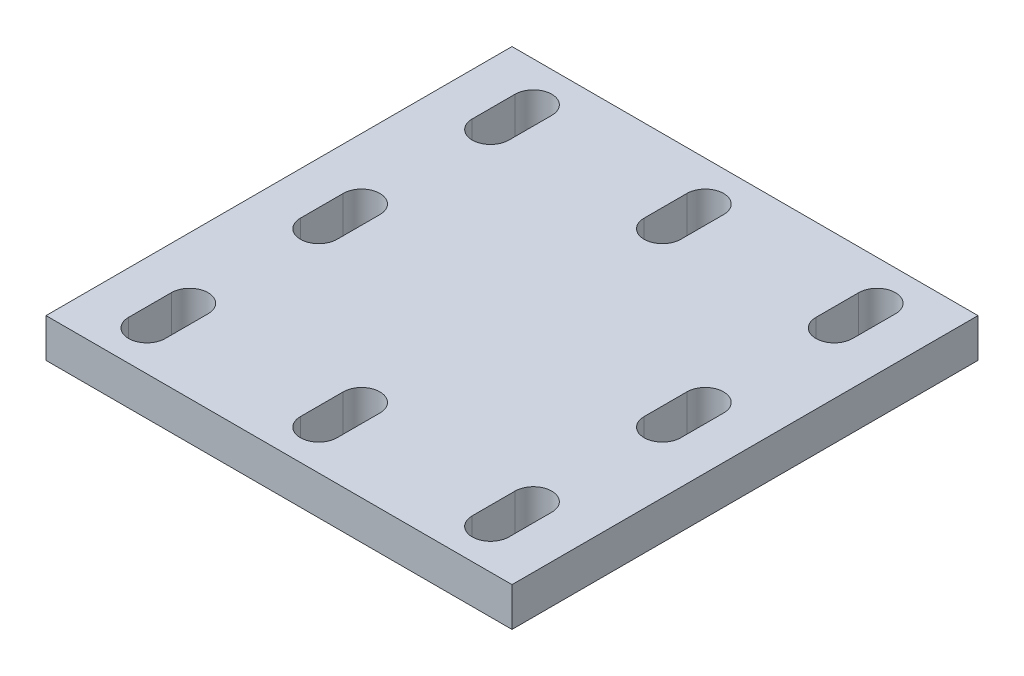
from build123d import *

# Parameters (mm, degrees)
SKETCH1_W           = 76.2
SKETCH1_H           = 76.2
BOSS_EXTRUDE1_DEPTH = 6.35
SKETCH2_R           = 3
BOSS_EXTRUDE2_DEPTH = 10
SKETCH3_R           = 1.5875
CUT_EXTRUDE1_DEPTH  = 10
CUT_EXTRUDE2_DEPTH  = 17.35


with BuildPart() as part:
    # Sketch1 → Boss-Extrude1 (new body)
    with BuildSketch(Plane(origin=(0, 0, 0), x_dir=(1, 0, 0), z_dir=(0, 1, 0))):
        Rectangle(SKETCH1_W, SKETCH1_H)
    extrude(amount=BOSS_EXTRUDE1_DEPTH)

    # Sketch2 → Boss-Extrude2 (add)
    with BuildSketch(Plane.XZ):
        Circle(SKETCH2_R)
    extrude(amount=BOSS_EXTRUDE2_DEPTH)

    # Sketch3 → Cut-Extrude1 (cut)
    with BuildSketch(Plane.XZ.offset(10)):
        Circle(SKETCH3_R)
    extrude(amount=-CUT_EXTRUDE1_DEPTH, mode=Mode.SUBTRACT)

    # Sketch5 → Cut-Extrude2 (cut, through all)
    with BuildSketch(Plane(origin=(0, 6.35, 0), x_dir=(1, 0, 0), z_dir=(0, 1, 0))):
        with BuildLine():
            Line((-25.1, 31.6), (-25.1, 24.6))
            ThreePointArc((-25.1, 24.6), (-28.1, 21.6), (-31.1, 24.6))
            Line((-31.1, 24.6), (-31.1, 31.6))
            ThreePointArc((-31.1, 31.6), (-28.1, 34.6), (-25.1, 31.6))
        make_face()
        with BuildLine():
            Line((-3, 31.6), (-3, 24.6))
            ThreePointArc((-3, 24.6), (0, 21.6), (3, 24.6))
            Line((3, 24.6), (3, 31.6))
            ThreePointArc((3, 31.6), (0, 34.6), (-3, 31.6))
        make_face()
        with BuildLine():
            Line((25.1, 31.6), (25.1, 24.6))
            ThreePointArc((25.1, 24.6), (28.1, 21.6), (31.1, 24.6))
            Line((31.1, 24.6), (31.1, 31.6))
            ThreePointArc((31.1, 31.6), (28.1, 34.6), (25.1, 31.6))
        make_face()
        with BuildLine():
            Line((25.1, 3.5), (25.1, -3.5))
            ThreePointArc((25.1, -3.5), (28.1, -6.5), (31.1, -3.5))
            Line((31.1, -3.5), (31.1, 3.5))
            ThreePointArc((31.1, 3.5), (28.1, 6.5), (25.1, 3.5))
        make_face()
        with BuildLine():
            Line((-3, -24.6), (-3, -31.6))
            ThreePointArc((-3, -31.6), (0, -34.6), (3, -31.6))
            Line((3, -31.6), (3, -24.6))
            ThreePointArc((3, -24.6), (0, -21.6), (-3, -24.6))
        make_face()
        with BuildLine():
            Line((25.1, -24.6), (25.1, -31.6))
            ThreePointArc((25.1, -31.6), (28.1, -34.6), (31.1, -31.6))
            Line((31.1, -31.6), (31.1, -24.6))
            ThreePointArc((31.1, -24.6), (28.1, -21.6), (25.1, -24.6))
        make_face()
        with BuildLine():
            Line((-31.1, 3.5), (-31.1, -3.5))
            ThreePointArc((-31.1, -3.5), (-28.1, -6.5), (-25.1, -3.5))
            Line((-25.1, -3.5), (-25.1, 3.5))
            ThreePointArc((-25.1, 3.5), (-28.1, 6.5), (-31.1, 3.5))
        make_face()
        with BuildLine():
            Line((-31.1, -24.6), (-31.1, -31.6))
            ThreePointArc((-31.1, -31.6), (-28.1, -34.6), (-25.1, -31.6))
            Line((-25.1, -31.6), (-25.1, -24.6))
            ThreePointArc((-25.1, -24.6), (-28.1, -21.6), (-31.1, -24.6))
        make_face()
    extrude(amount=-CUT_EXTRUDE2_DEPTH, mode=Mode.SUBTRACT)


solid = part.part
